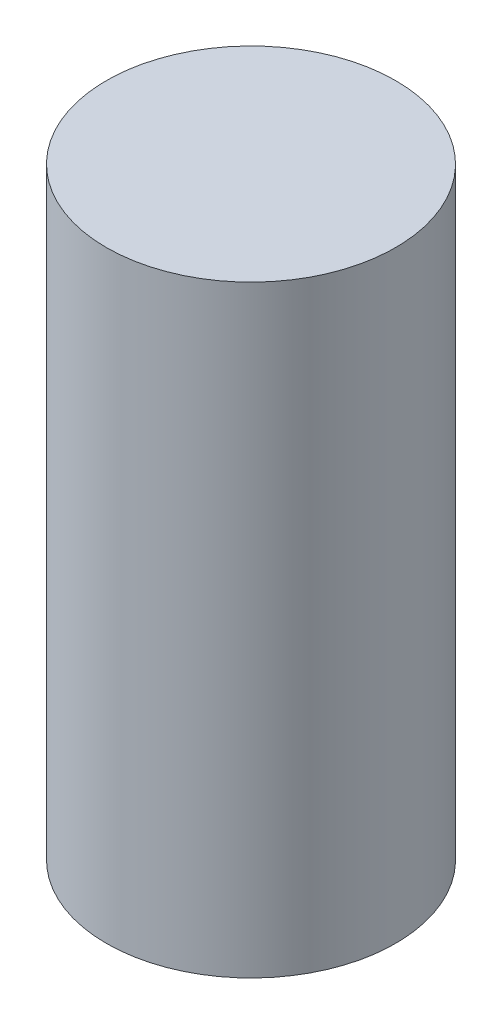
from build123d import *

# Parameters (mm, degrees)
SKETCH2_R           = 0.6
BOSS_EXTRUDE1_DEPTH = 2.5


with BuildPart() as part:
    # Sketch2 → Boss-Extrude1 (new body)
    with BuildSketch(Plane(origin=(0, 0, 0), x_dir=(1, 0, 0), z_dir=(0, 1, 0))):
        Circle(SKETCH2_R)
    extrude(amount=BOSS_EXTRUDE1_DEPTH)


solid = part.part
